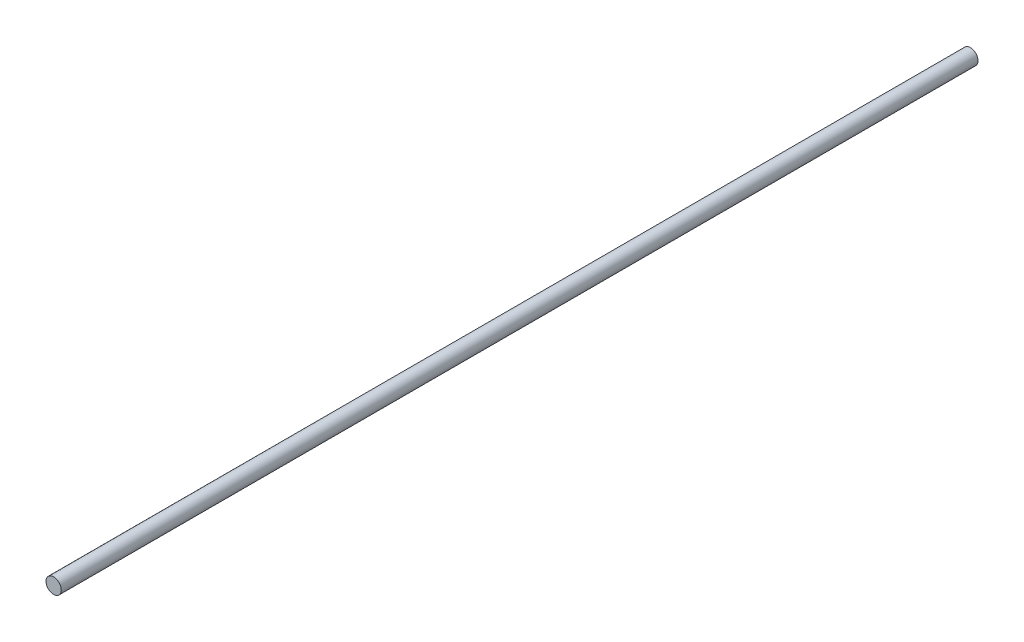
from build123d import *

# Parameters (mm, degrees)
ESBO_O1_R                = 2.5
RESSALTO_EXTRUS_O1_DEPTH = 150


with BuildPart() as part:
    # Esboço1 → Ressalto-extrusão1 (new body, symmetric)
    with BuildSketch(Plane.XY):
        Circle(ESBO_O1_R)
    extrude(amount=RESSALTO_EXTRUS_O1_DEPTH, both=True)


solid = part.part
